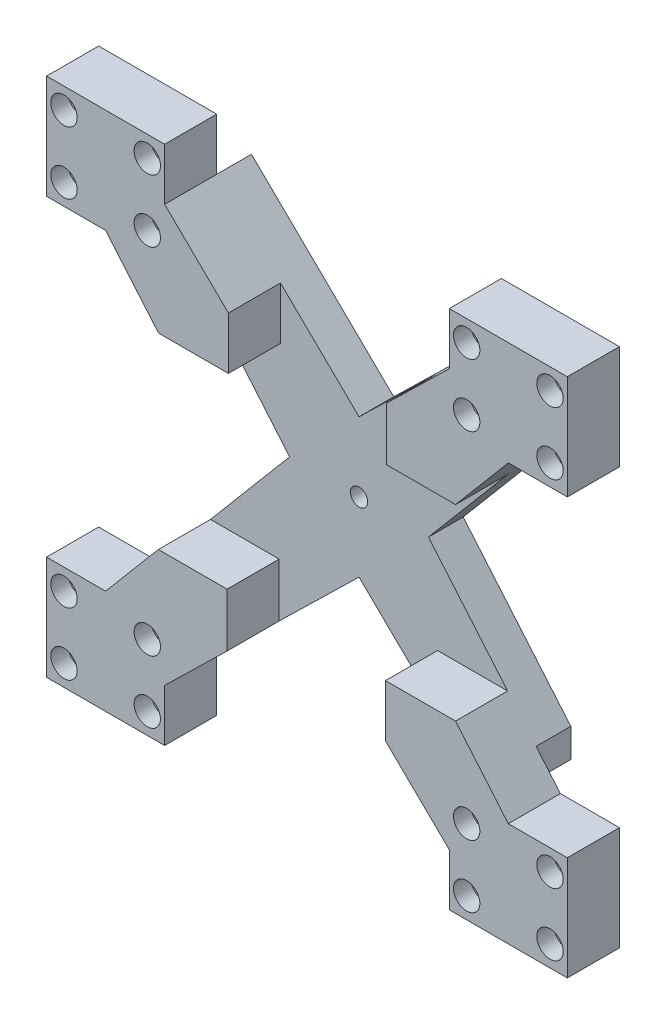
from build123d import *

# Parameters (mm, degrees)
SKETCH1_W           = 150
SKETCH1_H           = 150
BOSS_EXTRUDE1_DEPTH = 15
CUT_EXTRUDE1_DEPTH  = 15
BOSS_EXTRUDE2_DEPTH = 25
CUT_EXTRUDE2_DEPTH  = 15
SKETCH5_R           = 2.5
CUT_EXTRUDE3_DEPTH  = 15
SKETCH7_R           = 2.5
CUT_EXTRUDE4_DEPTH  = 15
SKETCH8_R           = 3.8
CUT_EXTRUDE5_DEPTH  = 5
SKETCH10_R          = 2.5
CUT_EXTRUDE6_DEPTH  = 26
SKETCH11_R          = 3.8
CUT_EXTRUDE7_DEPTH  = 5
SKETCH12_R          = 2.5
CUT_EXTRUDE8_DEPTH  = 26
SKETCH13_R          = 3.8
CUT_EXTRUDE9_DEPTH  = 5
SKETCH14_R          = 2.5
CUT_EXTRUDE10_DEPTH = 26
SKETCH15_R          = 3.8
CUT_EXTRUDE11_DEPTH = 5
BOSS_EXTRUDE3_DEPTH = 15
BOSS_EXTRUDE4_DEPTH = 15
BOSS_EXTRUDE5_DEPTH = 15
BOSS_EXTRUDE6_DEPTH = 15
SKETCH20_W          = 7
SKETCH20_H          = 10
CUT_EXTRUDE12_DEPTH = 151
SKETCH21_W          = 7
SKETCH21_H          = 10
CUT_EXTRUDE13_DEPTH = 121


with BuildPart() as part:
    # Sketch1 → Boss-Extrude1 (new body)
    with BuildSketch(Plane.XY):
        Rectangle(SKETCH1_W, SKETCH1_H)
    extrude(amount=BOSS_EXTRUDE1_DEPTH)

    # Sketch2 → Cut-Extrude1 (cut)
    with BuildSketch(Plane.XY.offset(15)):
        Polygon((-41, 75), (-41, 60), (0, 20), (41, 60), (41, 75), align=None)
        Polygon((-20, 0), (-58, 45), (-75, 45), (-75, -45), (-58, -45), align=None)
        Polygon((58, 45), (20, 0), (58, -45), (75, -45), (75, 45), align=None)
        Polygon((41, -60), (0, -20), (-41, -60), (-41, -75), (41, -75), align=None)
    extrude(amount=-CUT_EXTRUDE1_DEPTH, mode=Mode.SUBTRACT)

    # Sketch3 → Boss-Extrude2 (add)
    with BuildSketch(Plane.XY.offset(15)):
        Polygon((-41, 45.069428085), (-58, 45.069428085), (-20, 0), (-58, -45), (-41, -45), (-41, -60), (0, -20), (41, -60), (41, -45), (58, -45), (20, 0), (58, 45), (41, 45), (41, 60), (0, 20), (-41, 60), align=None)
    extrude(amount=-BOSS_EXTRUDE2_DEPTH)

    # Sketch4 → Cut-Extrude2 (cut)
    with BuildSketch(Plane.XY.offset(15)):
        Polygon((-38, -42), (-38, -57.073170732), (0, -20), (38, -57.073170732), (38, -42), (55.466666667, -42), (20, 0), (55.466666667, 42), (37.925, 42), (37.925, 57), (0, 20), (-37.220661316, 56.312840308), (-37.426275475, 56.513439488), (-38, 57.073170732), (-38, 42), (-55.466666667, 42), (-20, 0), (-55.466666667, -42), align=None)
    extrude(amount=-CUT_EXTRUDE2_DEPTH, mode=Mode.SUBTRACT)

    # Sketch5 → Cut-Extrude3 (cut)
    with BuildSketch(Plane.XY):
        Circle(SKETCH5_R)
    extrude(amount=-CUT_EXTRUDE3_DEPTH, mode=Mode.SUBTRACT)

    # Sketch7 → Cut-Extrude4 (cut)
    with BuildSketch(Plane.XY.offset(15)):
        with Locations((70, -51)):
            Circle(SKETCH7_R)
        with Locations((46, -51)):
            Circle(SKETCH7_R)
        with Locations((46, -69)):
            Circle(SKETCH7_R)
        with Locations((70, -69)):
            Circle(SKETCH7_R)
    extrude(amount=-CUT_EXTRUDE4_DEPTH, mode=Mode.SUBTRACT)

    # Sketch8 → Cut-Extrude5 (cut)
    with BuildSketch(Plane.XY.offset(15)):
        with Locations((46, -51)):
            Circle(SKETCH8_R)
        with Locations((70, -51)):
            Circle(SKETCH8_R)
        with Locations((70, -69)):
            Circle(SKETCH8_R)
        with Locations((46, -69)):
            Circle(SKETCH8_R)
    extrude(amount=-CUT_EXTRUDE5_DEPTH, mode=Mode.SUBTRACT)

    # Sketch10 → Cut-Extrude6 (cut, through all)
    with BuildSketch(Plane.XY.offset(15)):
        with Locations((-46, -69)):
            Circle(SKETCH10_R)
        with Locations((-46, -51)):
            Circle(SKETCH10_R)
        with Locations((-70, -51)):
            Circle(SKETCH10_R)
        with Locations((-70, -69)):
            Circle(SKETCH10_R)
    extrude(amount=-CUT_EXTRUDE6_DEPTH, mode=Mode.SUBTRACT)

    # Sketch11 → Cut-Extrude7 (cut)
    with BuildSketch(Plane.XY.offset(15)):
        with Locations((-70, -51)):
            Circle(SKETCH11_R)
        with Locations((-46, -51)):
            Circle(SKETCH11_R)
        with Locations((-70, -69)):
            Circle(SKETCH11_R)
        with Locations((-46, -69)):
            Circle(SKETCH11_R)
    extrude(amount=-CUT_EXTRUDE7_DEPTH, mode=Mode.SUBTRACT)

    # Sketch12 → Cut-Extrude8 (cut, through all)
    with BuildSketch(Plane.XY.offset(15)):
        with Locations((46, 69)):
            Circle(SKETCH12_R)
        with Locations((70, 69)):
            Circle(SKETCH12_R)
        with Locations((70, 51)):
            Circle(SKETCH12_R)
        with Locations((46, 51)):
            Circle(SKETCH12_R)
    extrude(amount=-CUT_EXTRUDE8_DEPTH, mode=Mode.SUBTRACT)

    # Sketch13 → Cut-Extrude9 (cut)
    with BuildSketch(Plane.XY.offset(15)):
        with Locations((70, 69)):
            Circle(SKETCH13_R)
        with Locations((46, 69)):
            Circle(SKETCH13_R)
        with Locations((46, 51)):
            Circle(SKETCH13_R)
        with Locations((70, 51)):
            Circle(SKETCH13_R)
    extrude(amount=-CUT_EXTRUDE9_DEPTH, mode=Mode.SUBTRACT)

    # Sketch14 → Cut-Extrude10 (cut, through all)
    with BuildSketch(Plane.XY.offset(15)):
        with Locations((-70, 69)):
            Circle(SKETCH14_R)
        with Locations((-46, 69)):
            Circle(SKETCH14_R)
        with Locations((-46, 51)):
            Circle(SKETCH14_R)
        with Locations((-70, 51)):
            Circle(SKETCH14_R)
    extrude(amount=-CUT_EXTRUDE10_DEPTH, mode=Mode.SUBTRACT)

    # Sketch15 → Cut-Extrude11 (cut)
    with BuildSketch(Plane.XY.offset(15)):
        with Locations((-70, 69)):
            Circle(SKETCH15_R)
        with Locations((-46, 69)):
            Circle(SKETCH15_R)
        with Locations((-46, 51)):
            Circle(SKETCH15_R)
        with Locations((-70, 51)):
            Circle(SKETCH15_R)
    extrude(amount=-CUT_EXTRUDE11_DEPTH, mode=Mode.SUBTRACT)

    # Sketch16 → Boss-Extrude3 (add)
    with BuildSketch(Plane.XY):
        Polygon((-38, -57.073170732), (-23, -42.43902439), (-23, -27), (-42.8, -27), (-55.466666667, -42), (-38, -42), align=None)
    extrude(amount=BOSS_EXTRUDE3_DEPTH)

    # Sketch17 → Boss-Extrude4 (add)
    with BuildSketch(Plane.XY):
        Polygon((38, -57.073170732), (22.625, -42.073170732), (22.625, -27), (42.8, -27), (55.466666667, -42), (38, -42), align=None)
    extrude(amount=BOSS_EXTRUDE4_DEPTH)

    # Sketch18 → Boss-Extrude5 (add)
    with BuildSketch(Plane.XY):
        Polygon((37.925, 57), (22.925, 42.365853659), (22.925, 27), (42.8, 27), (55.466666667, 42), (37.925, 42), align=None)
    extrude(amount=BOSS_EXTRUDE5_DEPTH)

    # Sketch19 → Boss-Extrude6 (add)
    with BuildSketch(Plane.XY):
        Polygon((-38, 57.073170732), (-22.625, 42.073170732), (-22.625, 27), (-42.764877292, 27), (-55.466666667, 42), (-38, 42), align=None)
    extrude(amount=BOSS_EXTRUDE6_DEPTH)

    # Sketch20 → Cut-Extrude12 (cut, through all)
    with BuildSketch(Plane.XZ.offset(75)):
        with Locations((54.5, -5)):
            Rectangle(SKETCH20_W, SKETCH20_H)
    extrude(amount=-CUT_EXTRUDE12_DEPTH, mode=Mode.SUBTRACT)

    # Sketch21 → Cut-Extrude13 (cut, through all)
    with BuildSketch(Plane.XZ.offset(45)):
        with Locations((-54.5, -5)):
            Rectangle(SKETCH21_W, SKETCH21_H)
    extrude(amount=-CUT_EXTRUDE13_DEPTH, mode=Mode.SUBTRACT)


solid = part.part
